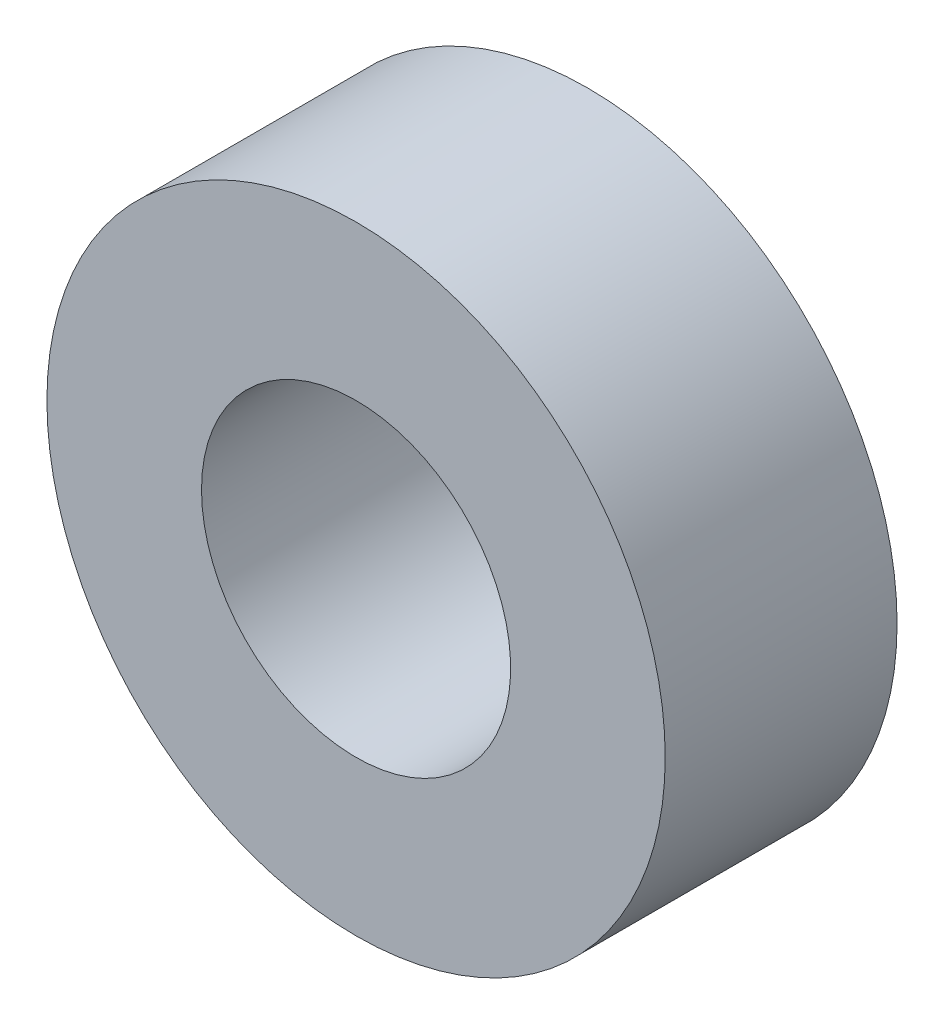
from build123d import *

# Parameters (mm, degrees)
SKETCH1_R      = 6.35
EXTRUDE1_DEPTH = 4.7625
SKETCH2_R      = 3.175
EXTRUDE2_DEPTH = 5.7625


with BuildPart() as part:
    # Sketch1 → Extrude1 (new body)
    with BuildSketch(Plane.XY):
        Circle(SKETCH1_R)
    extrude(amount=EXTRUDE1_DEPTH)

    # Sketch2 → Extrude2 (cut, through all)
    with BuildSketch(Plane(origin=(0, 0, 0), x_dir=(-1, 0, 0), z_dir=(0, 0, -1))):
        Circle(SKETCH2_R)
    extrude(amount=-EXTRUDE2_DEPTH, mode=Mode.SUBTRACT)


solid = part.part
